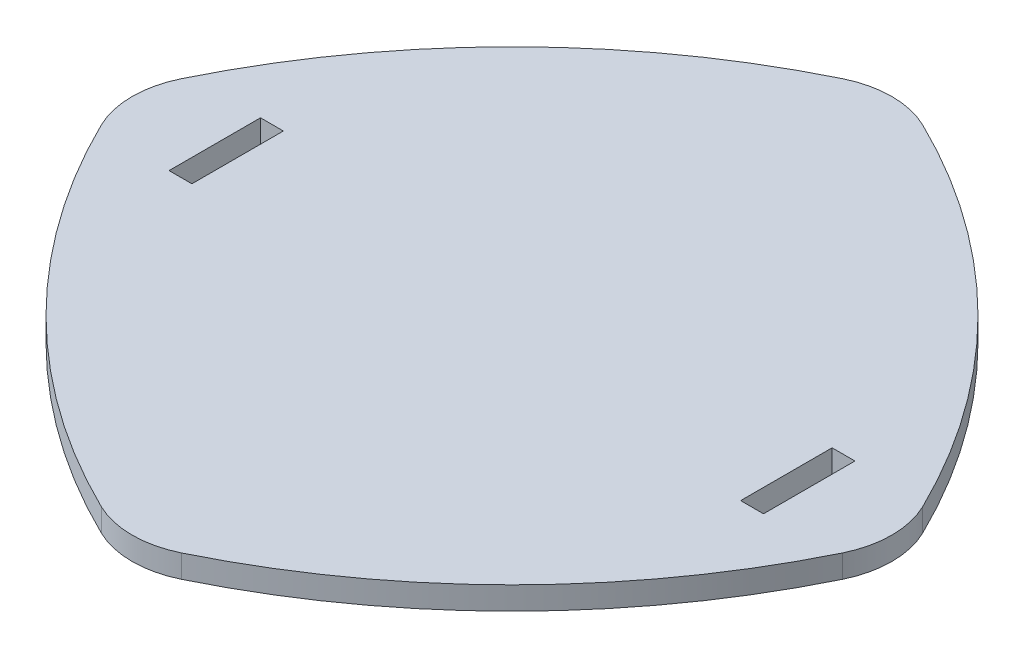
from build123d import *

# Parameters (mm, degrees)
BOSS_EXTRUDE1_DEPTH = 0.25
FILLET1_R           = 2
CUT_EXTRUDE1_REACH  = 2.5
SKETCH2_W           = 0.5
SKETCH2_H           = 2


with BuildPart() as part:
    # Sketch1 → Boss-Extrude1 (new body, symmetric)
    with BuildSketch(Plane(origin=(0, 0, 0), x_dir=(1, 0, 0), z_dir=(0, 1, 0))):
        with BuildLine():
            ThreePointArc((-8.5, 0), (-5.095377561, 5.095377561), (0, 8.5))
            ThreePointArc((0, 8.5), (5.095377561, 5.095377561), (8.5, 0))
            ThreePointArc((8.5, 0), (5.095377561, -5.095377561), (0, -8.5))
            ThreePointArc((0, -8.5), (-5.095377561, -5.095377561), (-8.5, 0))
        make_face()
    extrude(amount=BOSS_EXTRUDE1_DEPTH, both=True)

    # Fillet1
    fillet1_edges = [part.edges().sort_by_distance(p)[0] for p in [
        (-8.5, 0, 0),
        (0, 0, -8.5),
        (8.5, 0, 0),
        (0, 0, 8.5),
    ]]
    fillet(fillet1_edges, radius=FILLET1_R)

    # Sketch2 → Cut-Extrude1 (cut, up to next)
    with BuildSketch(Plane(origin=(0, 0.25, 0), x_dir=(1, 0, 0), z_dir=(0, 1, 0)), mode=Mode.PRIVATE) as cut_extrude1_sk1:
        with Locations((-6.25, 0)):
            Rectangle(SKETCH2_W, SKETCH2_H)
    cut_extrude1_tool1 = extrude(cut_extrude1_sk1.sketch, amount=-CUT_EXTRUDE1_REACH, mode=Mode.PRIVATE) & part.part
    add(cut_extrude1_tool1.solids().sort_by_distance((-6.25, 0.25, 0))[0], mode=Mode.SUBTRACT)
    # Sketch2 → Cut-Extrude1 (cut, up to next)
    with BuildSketch(Plane(origin=(0, 0.25, 0), x_dir=(1, 0, 0), z_dir=(0, 1, 0)), mode=Mode.PRIVATE) as cut_extrude1_sk2:
        with Locations((6.25, 0)):
            Rectangle(SKETCH2_W, SKETCH2_H)
    cut_extrude1_tool2 = extrude(cut_extrude1_sk2.sketch, amount=-CUT_EXTRUDE1_REACH, mode=Mode.PRIVATE) & part.part
    add(cut_extrude1_tool2.solids().sort_by_distance((6.25, 0.25, 0))[0], mode=Mode.SUBTRACT)


solid = part.part
